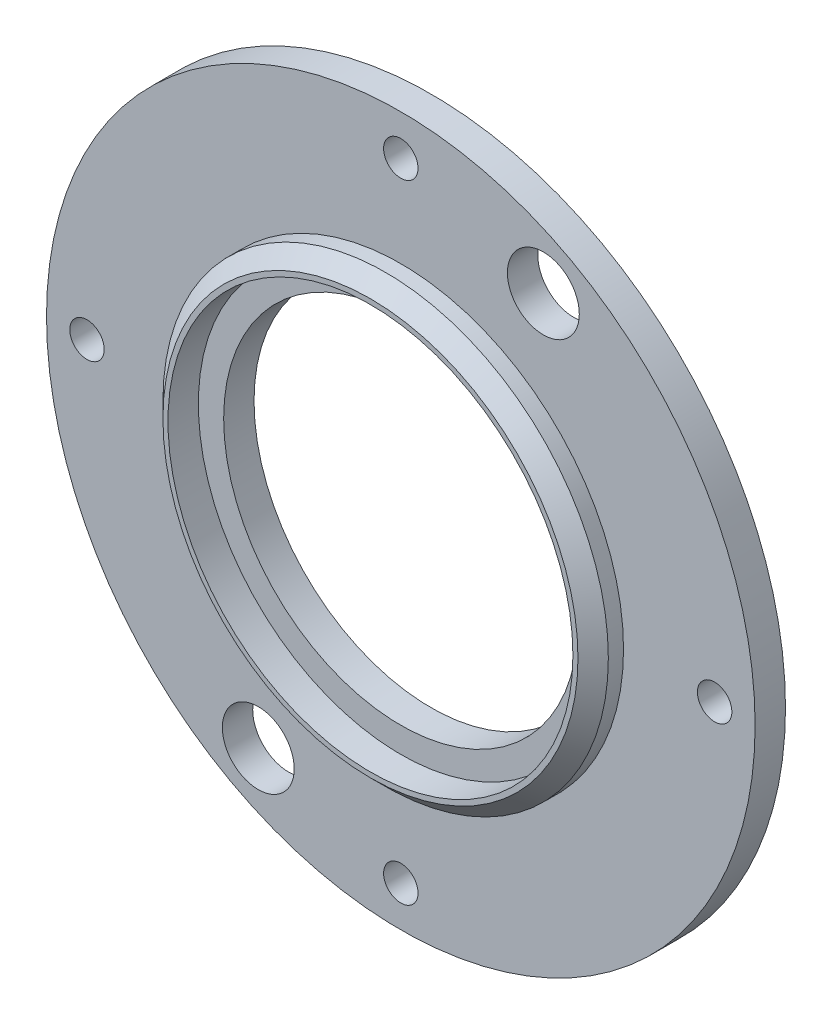
from build123d import *

# Parameters (mm, degrees)
SKIZZE1_R                        = 35
SKIZZE1_R_2                      = 17.5
AUFSATZ_LINEAR_AUSTRAGEN1_DEPTH  = 3
SKIZZE2_R                        = 22
SKIZZE2_R_2                      = 20
AUFSATZ_LINEAR_AUSTRAGEN2_DEPTH  = 3
FASE1_SIZE                       = 1.5
KREISMUSTER2_COUNT               = 4
F_7_1_7_1_DURCHMESSER_BOHRUNG1_D = 7.1
KREISMUSTER3_COUNT               = 2


with BuildPart() as part:
    # Skizze1 → Aufsatz-Linear austragen1 (new body)
    with BuildSketch(Plane.XY):
        Circle(SKIZZE1_R)
        Circle(SKIZZE1_R_2, mode=Mode.SUBTRACT)
    extrude(amount=AUFSATZ_LINEAR_AUSTRAGEN1_DEPTH)

    # Skizze2 → Aufsatz-Linear austragen2 (add)
    with BuildSketch(Plane.XY.offset(3)):
        Circle(SKIZZE2_R)
        Circle(SKIZZE2_R_2, mode=Mode.SUBTRACT)
    extrude(amount=AUFSATZ_LINEAR_AUSTRAGEN2_DEPTH)

    # Fase1
    fase1_edges = [part.edges().sort_by_distance(p)[0] for p in [
        (-22, 0, 6),
    ]]
    chamfer(fase1_edges, length=FASE1_SIZE)

    # Skizze4 → Ø3.4 (3.4) Durchmesser Bohrung1 (revolve, cut)
    with BuildSketch(Plane(origin=(0, 31, 0), x_dir=(0, 1, 0), z_dir=(1, 0, 0))):
        Polygon((0, 0), (0, 11.021463052), (1.7, 10), (1.7, 0), align=None)
    f_3_4_3_4_durchmesser_bohrung1 = revolve(axis=Axis((0, 31, -6.35), (0, 0, 1)), mode=Mode.SUBTRACT)

    # Kreismuster2: Ø3.4 (3.4) Durchmesser Bohrung1 ×4 about axis
    kreismuster2_axis = Axis((0, 0, 3), (0, 0, -1))
    for i in range(1, KREISMUSTER2_COUNT):
        add(f_3_4_3_4_durchmesser_bohrung1.rotate(kreismuster2_axis, i * 360 / KREISMUSTER2_COUNT), mode=Mode.SUBTRACT)

    # Ø7.1 (7.1) Durchmesser Bohrung1 (through all)
    with Locations(Plane(origin=(0, 0, 0), x_dir=(-1, 0, 0), z_dir=(0, 0, -1))):
        with Locations((-14.08, 26.49)):
            f_7_1_7_1_durchmesser_bohrung1 = Hole(F_7_1_7_1_DURCHMESSER_BOHRUNG1_D / 2)

    # Kreismuster3: Ø7.1 (7.1) Durchmesser Bohrung1 ×2 about axis
    kreismuster3_axis = Axis((0, 0, 0), (0, 0, 1))
    for i in range(1, KREISMUSTER3_COUNT):
        add(f_7_1_7_1_durchmesser_bohrung1.rotate(kreismuster3_axis, i * 360 / KREISMUSTER3_COUNT), mode=Mode.SUBTRACT)


solid = part.part
